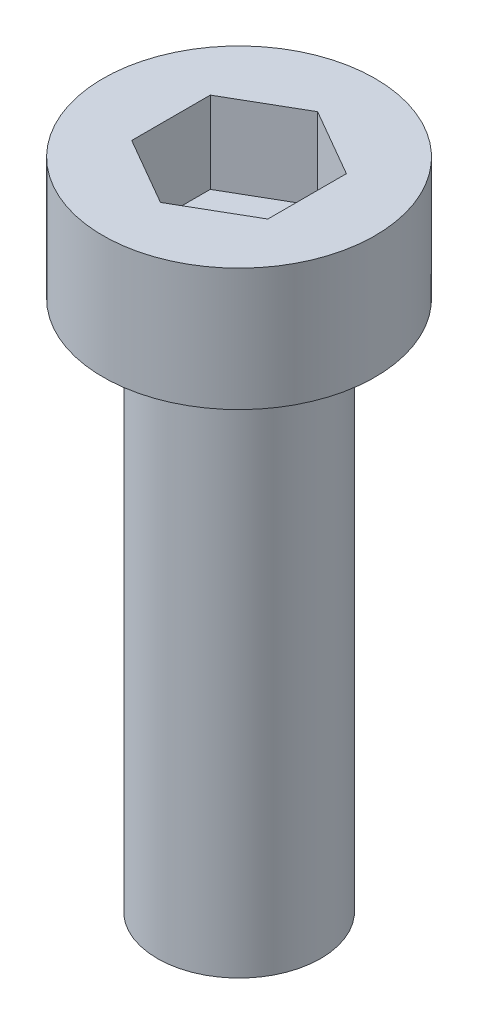
from build123d import *

# Parameters (mm, degrees)
WYTNIJ_WYCI_GNI_CIE1_DEPTH = 3


with BuildPart() as part:
    # Szkic1 → Obrót1 (revolve)
    with BuildSketch(Plane.XY):
        Polygon((0, 0), (5, 0), (5, -4.5), (3, -4.5), (3, -14.5), (3, -24), (2.5, -24), (0, -24), align=None)
    revolve(axis=Axis((0, 0, 0), (0, 1, 0)))

    # Szkic2 → Wytnij-wyciągnięcie1 (cut)
    with BuildSketch(Plane(origin=(0, 0, 0), x_dir=(1, 0, 0), z_dir=(0, 1, 0))):
        Polygon((0, 2.886751346), (-2.5, 1.443375673), (-2.5, -1.443375673), (0, -2.886751346), (2.5, -1.443375673), (2.5, 1.443375673), align=None)
    extrude(amount=-WYTNIJ_WYCI_GNI_CIE1_DEPTH, mode=Mode.SUBTRACT)


solid = part.part
